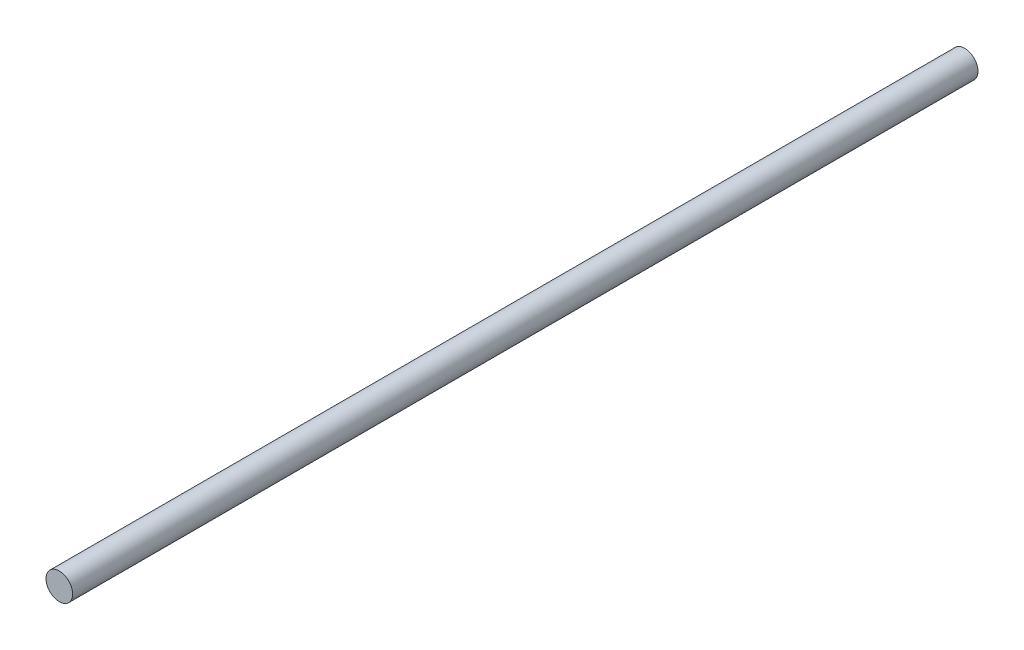
from build123d import *

# Parameters (mm, degrees)
SKETCH1_R           = 4
BOSS_EXTRUDE1_DEPTH = 272


with BuildPart() as part:
    # Sketch1 → Boss-Extrude1 (new body)
    with BuildSketch(Plane.XY):
        with Locations((-582.369900344, 124.910580717)):
            Circle(SKETCH1_R)
    extrude(amount=BOSS_EXTRUDE1_DEPTH)


solid = part.part
